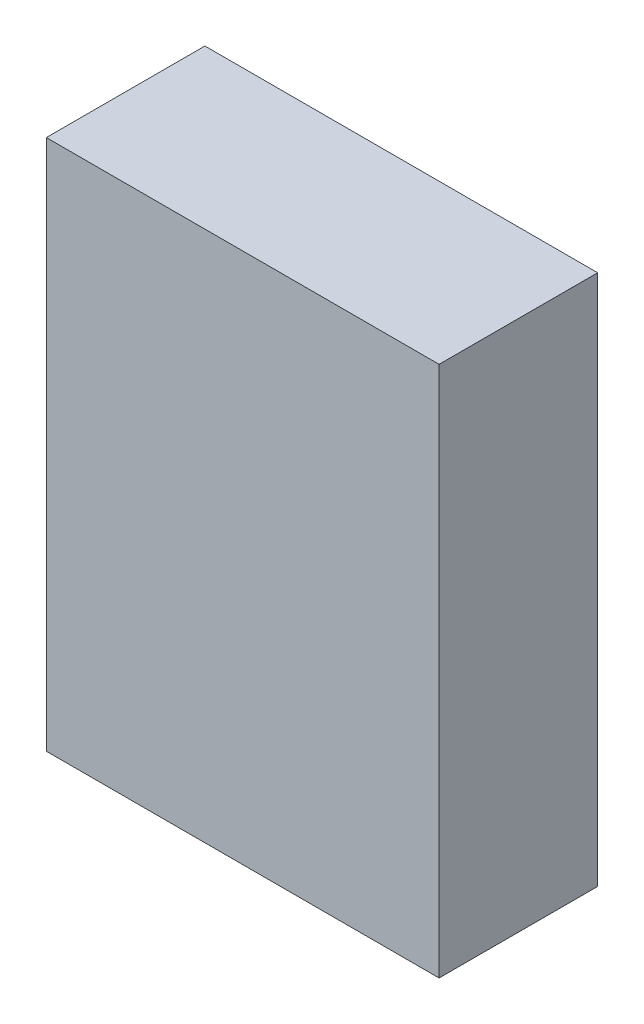
from build123d import *

# Parameters (mm, degrees)
BOSS_EXTRUDE1_DEPTH = 25.769


with BuildPart() as part:
    # Sketch1 → Boss-Extrude1 (new body)
    with BuildSketch(Plane.XY):
        Polygon((33.831936686, 43.18), (33.831936686, -43.18), (-29.99, -43.18), (-29.99, 0), (-29.99, 43.18), align=None)
    extrude(amount=BOSS_EXTRUDE1_DEPTH)


solid = part.part
